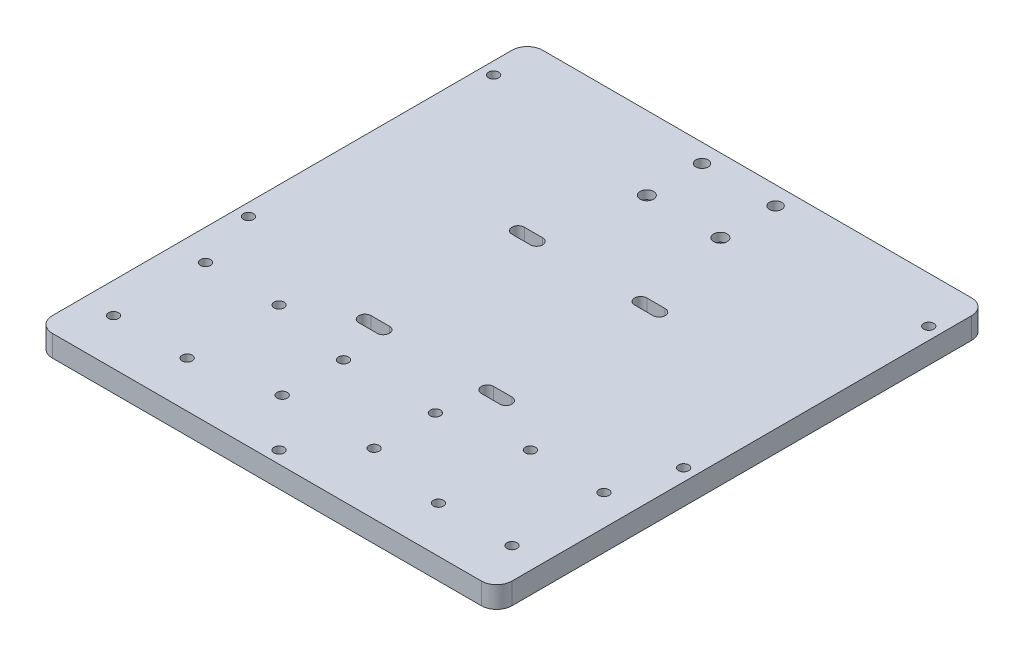
from build123d import *

# Parameters (mm, degrees)
SKETCH_2_W           = 150
SKETCH_2_H           = 160
EXTRUDE_1_DEPTH      = 7
FILLET_1_R           = 5
SKETCH_3_R           = 1.65
CUT_EXTRUDE_1_DEPTH  = 8
SKETCH_6_R           = 2.02
SKETCH_6_R_2         = 2.2
CUT_EXTRUDE_2_DEPTH  = 8
SKETCH_9_R           = 3.15
CUT_EXTRUDE_4_DEPTH  = 3.5
SKETCH_10_R          = 3.75
CUT_EXTRUDE_5_DEPTH  = 4.2
CUT_EXTRUDE_6_DEPTH  = 8
SKETCH_12_R          = 1.65
CUT_EXTRUDE_7_DEPTH  = 50
SKETCH_14_R          = 3
CUT_EXTRUDE_9_DEPTH  = 3.3
SKETCH_15_R          = 1.65
CUT_EXTRUDE_10_DEPTH = 8
SKETCH_16_R          = 3
CUT_EXTRUDE_11_DEPTH = 3.3


with BuildPart() as part:
    # 草图2 → 凸台-拉伸1 (new body)
    with BuildSketch(Plane(origin=(0, 0, 0), x_dir=(1, 0, 0), z_dir=(0, 1, 0))):
        Rectangle(SKETCH_2_W, SKETCH_2_H)
    extrude(amount=EXTRUDE_1_DEPTH)

    # 圆角1
    fillet_1_edges = [part.edges().sort_by_distance(p)[0] for p in [
        (75, 3.5, 80),
        (-75, 3.5, 80),
        (-75, 3.5, -80),
        (75, 3.5, -80),
    ]]
    fillet(fillet_1_edges, radius=FILLET_1_R)

    # 草图3 → 切除-拉伸1 (cut, through all)
    with BuildSketch(Plane(origin=(0, 7, 0), x_dir=(1, 0, 0), z_dir=(0, 1, 0))):
        with Locations((-65, -35)):
            Circle(SKETCH_3_R)
        with Locations((-41, -35)):
            Circle(SKETCH_3_R)
        with Locations((-41, -65)):
            Circle(SKETCH_3_R)
        with Locations((-65, -65)):
            Circle(SKETCH_3_R)
        with Locations((65, -65)):
            Circle(SKETCH_3_R)
        with Locations((41, -65)):
            Circle(SKETCH_3_R)
        with Locations((41, -35)):
            Circle(SKETCH_3_R)
        with Locations((65, -35)):
            Circle(SKETCH_3_R)
        with Locations((-15, -40)):
            Circle(SKETCH_3_R)
        with Locations((-15, -60)):
            Circle(SKETCH_3_R)
        with Locations((15, -60)):
            Circle(SKETCH_3_R)
        with Locations((15, -40)):
            Circle(SKETCH_3_R)
    extrude(amount=-CUT_EXTRUDE_1_DEPTH, mode=Mode.SUBTRACT)

    # 草图6 → 切除-拉伸2 (cut, through all)
    with BuildSketch(Plane(origin=(0, 7, 0), x_dir=(1, 0, 0), z_dir=(0, 1, 0))):
        with Locations((12, 74)):
            Circle(SKETCH_6_R)
        with Locations((12, 56)):
            Circle(SKETCH_6_R_2)
        with Locations((-12, 56)):
            Circle(SKETCH_6_R_2)
        with Locations((-12, 74)):
            Circle(SKETCH_6_R)
    extrude(amount=-CUT_EXTRUDE_2_DEPTH, mode=Mode.SUBTRACT)

    # 草图9 → 切除-拉伸4 (cut)
    with BuildSketch(Plane.XZ):
        with Locations((-15, 60)):
            Circle(SKETCH_9_R)
        with Locations((-15, 40)):
            Circle(SKETCH_9_R)
        with Locations((15, 60)):
            Circle(SKETCH_9_R)
        with Locations((15, 40)):
            Circle(SKETCH_9_R)
        Polygon((-39.325684219, 67.9), (-37.651368439, 65), (-39.325684219, 62.1), (-42.674315781, 62.1), (-44.348631561, 65), (-42.674315781, 67.9), align=None)
        Polygon((61.651368439, 35), (63.325684219, 32.1), (66.674315781, 32.1), (68.348631561, 35), (66.674315781, 37.9), (63.325684219, 37.9), align=None)
        Polygon((37.651368439, 35), (39.325684219, 32.1), (42.674315781, 32.1), (44.348631561, 35), (42.674315781, 37.9), (39.325684219, 37.9), align=None)
        Polygon((61.651368439, 65), (63.325684219, 62.1), (66.674315781, 62.1), (68.348631561, 65), (66.674315781, 67.9), (63.325684219, 67.9), align=None)
        Polygon((37.651368439, 65), (39.325684219, 62.1), (42.674315781, 62.1), (44.348631561, 65), (42.674315781, 67.9), (39.325684219, 67.9), align=None)
        Polygon((-63.325684219, 67.9), (-61.651368439, 65), (-63.325684219, 62.1), (-66.674315781, 62.1), (-68.348631561, 65), (-66.674315781, 67.9), align=None)
        Polygon((-39.325684219, 37.9), (-37.651368439, 35), (-39.325684219, 32.1), (-42.674315781, 32.1), (-44.348631561, 35), (-42.674315781, 37.9), align=None)
        Polygon((-63.325684219, 37.9), (-61.651368439, 35), (-63.325684219, 32.1), (-66.674315781, 32.1), (-68.348631561, 35), (-66.674315781, 37.9), align=None)
    extrude(amount=-CUT_EXTRUDE_4_DEPTH, mode=Mode.SUBTRACT)

    # 草图10 → 切除-拉伸5 (cut)
    with BuildSketch(Plane.XZ):
        with Locations((12, -74)):
            Circle(SKETCH_10_R)
        with Locations((12, -56)):
            Circle(SKETCH_10_R)
        with Locations((-12, -56)):
            Circle(SKETCH_10_R)
        with Locations((-12, -74)):
            Circle(SKETCH_10_R)
    extrude(amount=-CUT_EXTRUDE_5_DEPTH, mode=Mode.SUBTRACT)

    # 草图11 → 切除-拉伸6 (cut, through all)
    with BuildSketch(Plane(origin=(0, 7, 0), x_dir=(1, 0, 0), z_dir=(0, 1, 0))):
        with BuildLine():
            Line((17, 27), (23, 27))
            ThreePointArc((23, 27), (25, 25), (23, 23))
            Line((23, 23), (17, 23))
            ThreePointArc((17, 23), (15, 25), (17, 27))
        make_face()
        with BuildLine():
            Line((-17, 27), (-23, 27))
            ThreePointArc((-23, 27), (-25, 25), (-23, 23))
            Line((-23, 23), (-17, 23))
            ThreePointArc((-17, 23), (-15, 25), (-17, 27))
        make_face()
        with BuildLine():
            Line((17, -27), (23, -27))
            ThreePointArc((23, -27), (25, -25), (23, -23))
            Line((23, -23), (17, -23))
            ThreePointArc((17, -23), (15, -25), (17, -27))
        make_face()
        with BuildLine():
            Line((-17, -27), (-23, -27))
            ThreePointArc((-23, -27), (-25, -25), (-23, -23))
            Line((-23, -23), (-17, -23))
            ThreePointArc((-17, -23), (-15, -25), (-17, -27))
        make_face()
    extrude(amount=-CUT_EXTRUDE_6_DEPTH, mode=Mode.SUBTRACT)

    # 草图12 → 切除-拉伸7 (cut)
    with BuildSketch(Plane.XZ):
        with Locations((-71, -65)):
            Circle(SKETCH_12_R)
        with Locations((-71, 15)):
            Circle(SKETCH_12_R)
        with Locations((71, 15)):
            Circle(SKETCH_12_R)
        with Locations((71, -65)):
            Circle(SKETCH_12_R)
    extrude(amount=-CUT_EXTRUDE_7_DEPTH, mode=Mode.SUBTRACT)

    # 草图14 → 切除-拉伸9 (cut)
    with BuildSketch(Plane.XZ):
        with Locations((-71, -65)):
            Circle(SKETCH_14_R)
        with Locations((-71, 15)):
            Circle(SKETCH_14_R)
        with Locations((71, -65)):
            Circle(SKETCH_14_R)
        with Locations((71, 15)):
            Circle(SKETCH_14_R)
    extrude(amount=-CUT_EXTRUDE_9_DEPTH, mode=Mode.SUBTRACT)

    # 草图15 → 切除-拉伸10 (cut, through all)
    with BuildSketch(Plane.XZ):
        with Locations((0, 76)):
            Circle(SKETCH_15_R)
    extrude(amount=-CUT_EXTRUDE_10_DEPTH, mode=Mode.SUBTRACT)

    # 草图16 → 切除-拉伸11 (cut)
    with BuildSketch(Plane.XZ):
        with Locations((0, 76)):
            Circle(SKETCH_16_R)
    extrude(amount=-CUT_EXTRUDE_11_DEPTH, mode=Mode.SUBTRACT)


solid = part.part
